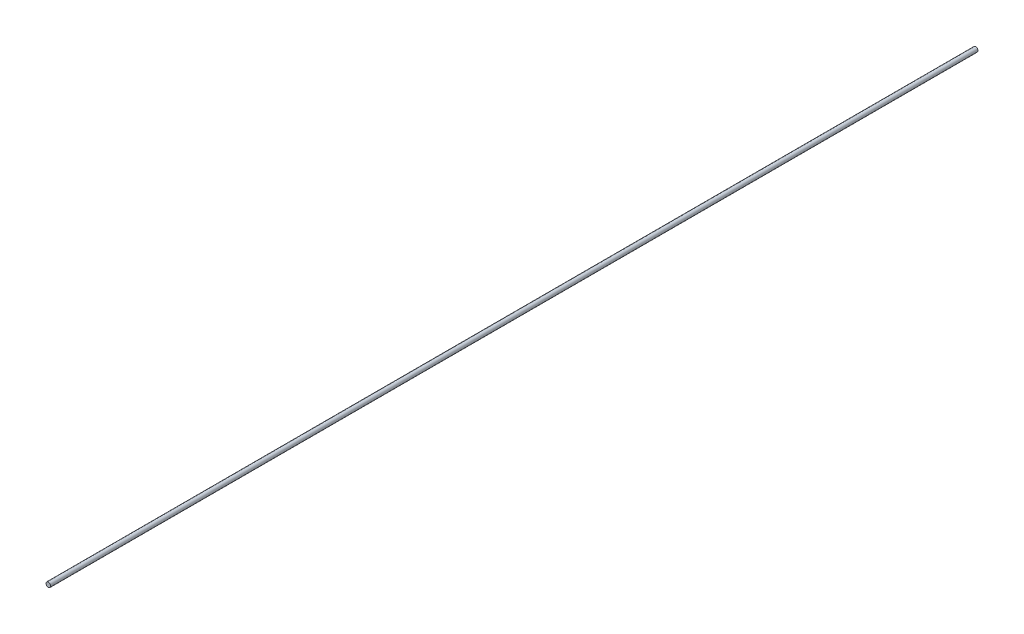
from build123d import *

# Parameters (mm, degrees)
SKETCH1_R           = 2.54
BOSS_EXTRUDE1_DEPTH = 1016


with BuildPart() as part:
    # Sketch1 → Boss-Extrude1 (new body)
    with BuildSketch(Plane.XY):
        Circle(SKETCH1_R)
    extrude(amount=BOSS_EXTRUDE1_DEPTH)


solid = part.part
